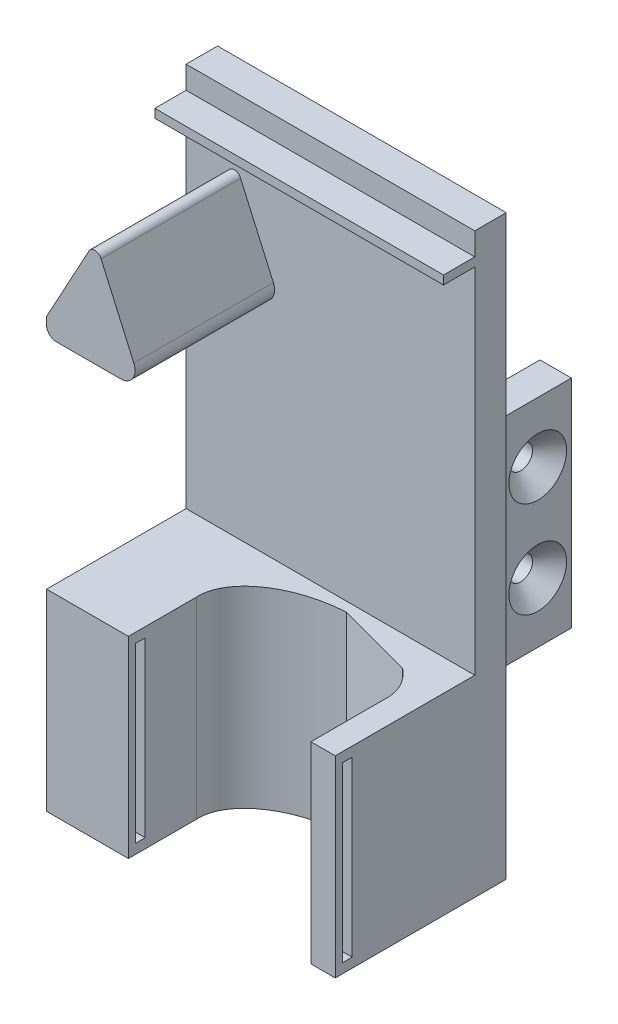
from build123d import *

# Parameters (mm, degrees)
SKETCH1_W                                       = 60
SKETCH1_H                                       = 120
BOSS_EXTRUDE1_DEPTH                             = 6.54
SKETCH10_W                                      = 6.54
SKETCH10_H                                      = 45
BOSS_EXTRUDE5_DEPTH                             = 17
SKETCH17_W                                      = 60
SKETCH17_H                                      = 40
BOSS_EXTRUDE6_DEPTH                             = 29
CUT_EXTRUDE1_REACH                              = 42
CUT_EXTRUDE2_REACH                              = 54.54
SKETCH21_W                                      = 37.9445377
SKETCH21_H                                      = 40
SKETCH23_W                                      = 2
SKETCH23_H                                      = 36
CUT_EXTRUDE3_DEPTH                              = 9
SKETCH24_W                                      = 2
SKETCH24_H                                      = 36
CUT_EXTRUDE4_DEPTH                              = 9
CSK_FOR_M3_FLAT_HEAD_MACHINE_SCREW4_D           = 4.93
CSK_FOR_M3_FLAT_HEAD_MACHINE_SCREW4_DEPTH       = 6.54
CSK_FOR_M3_FLAT_HEAD_MACHINE_SCREW4_CSINK_D     = 12
CSK_FOR_M3_FLAT_HEAD_MACHINE_SCREW4_CSINK_ANGLE = 90
CSK_FOR_M3_FLAT_HEAD_MACHINE_SCREW5_D           = 4.93
CSK_FOR_M3_FLAT_HEAD_MACHINE_SCREW5_DEPTH       = 6.54
CSK_FOR_M3_FLAT_HEAD_MACHINE_SCREW5_CSINK_D     = 12
CSK_FOR_M3_FLAT_HEAD_MACHINE_SCREW5_CSINK_ANGLE = 90
BOSS_EXTRUDE8_DEPTH                             = 29
SKETCH36_W                                      = 60
SKETCH36_H                                      = 1.8
BOSS_EXTRUDE9_DEPTH                             = 6.5
FILLET1_R                                       = 3
FILLET2_R                                       = 2


with BuildPart() as part:
    # Sketch1 → Boss-Extrude1 (new body)
    with BuildSketch(Plane.XY):
        Rectangle(SKETCH1_W, SKETCH1_H)
    extrude(amount=BOSS_EXTRUDE1_DEPTH)

    # Sketch10 → Boss-Extrude5 (add)
    with BuildSketch(Plane(origin=(0, 0, 0), x_dir=(-1, 0, 0), z_dir=(0, 0, -1))):
        with Locations((23.27, -2.5)):
            Rectangle(SKETCH10_W, SKETCH10_H)
        with Locations((-23.27, -2.5)):
            Rectangle(SKETCH10_W, SKETCH10_H)
    extrude(amount=BOSS_EXTRUDE5_DEPTH)

    # Sketch17 → Boss-Extrude6 (add)
    with BuildSketch(Plane.XY.offset(6.54)):
        with Locations((0, -40)):
            Rectangle(SKETCH17_W, SKETCH17_H)
    extrude(amount=BOSS_EXTRUDE6_DEPTH)

    # Sketch18 → Cut-Extrude1 (cut, up to next)
    with BuildSketch(Plane(origin=(0, -20, 0), x_dir=(1, 0, 0), z_dir=(0, 1, 0)), mode=Mode.PRIVATE) as cut_extrude1_sk1:
        with BuildLine():
            Line((5.334966353, -8.526396136), (21.291300905, -12.825812438))
            add(Edge.make_bspline(
                [(5.334966353, -8.526396136), (-17.854714365, -9.780670981), (-12.49786254, -23.648890313), (-7.141010715, -37.517109645), (13.926544327, -30.768916863), (34.994099369, -24.020724082), (21.291300905, -12.825812438)],
                knots=[1.570796327, 1.570796327, 1.570796327, 3.340987112, 3.340987112, 5.111177898, 5.111177898, 6.881368684, 6.881368684, 6.881368684], degree=2, weights=[1, 0.633215673, 1, 0.633215673, 1, 0.633215673, 1]))
        make_face()
    cut_extrude1_tool1 = extrude(cut_extrude1_sk1.sketch, amount=-CUT_EXTRUDE1_REACH, mode=Mode.PRIVATE) & part.part
    add(cut_extrude1_tool1.solids().sort_by_distance((5.792514, -20, 20.554542))[0], mode=Mode.SUBTRACT)

    # Sketch21 → Cut-Extrude2 (cut, up to next)
    with BuildSketch(Plane.XY.offset(35.54), mode=Mode.PRIVATE) as cut_extrude2_sk1:
        with Locations((5.97226885, -40)):
            Rectangle(SKETCH21_W, SKETCH21_H)
    cut_extrude2_tool1 = extrude(cut_extrude2_sk1.sketch, amount=-CUT_EXTRUDE2_REACH, mode=Mode.PRIVATE) & part.part
    add(cut_extrude2_tool1.solids().sort_by_distance((5.972269, -40, 35.54))[0], mode=Mode.SUBTRACT)

    # Sketch23 → Cut-Extrude3 (cut)
    with BuildSketch(Plane(origin=(-13, 0, 0), x_dir=(0, 0, -1), z_dir=(1, 0, 0))):
        with Locations((-33.04, -40)):
            Rectangle(SKETCH23_W, SKETCH23_H)
    extrude(amount=-CUT_EXTRUDE3_DEPTH, mode=Mode.SUBTRACT)

    # Sketch24 → Cut-Extrude4 (cut)
    with BuildSketch(Plane.ZY.offset(-24.9445377)):
        with Locations((33.04, -40)):
            Rectangle(SKETCH24_W, SKETCH24_H)
    extrude(amount=-CUT_EXTRUDE4_DEPTH, mode=Mode.SUBTRACT)

    # CSK for M3 Flat Head Machine Screw4
    with Locations(Plane(origin=(26.54, -12.5, -10), x_dir=(0, 1, 0), z_dir=(1, 0, 0))):
        with Locations((0, 0), (20, 0)):
            CounterSinkHole(CSK_FOR_M3_FLAT_HEAD_MACHINE_SCREW4_D / 2, CSK_FOR_M3_FLAT_HEAD_MACHINE_SCREW4_CSINK_D / 2, depth=CSK_FOR_M3_FLAT_HEAD_MACHINE_SCREW4_DEPTH, counter_sink_angle=CSK_FOR_M3_FLAT_HEAD_MACHINE_SCREW4_CSINK_ANGLE)

    # CSK for M3 Flat Head Machine Screw5
    with Locations(Plane(origin=(-26.54, -12.5, -10), x_dir=(0, -1, 0), z_dir=(-1, 0, 0))):
        with Locations((0, 0), (-20, 0)):
            CounterSinkHole(CSK_FOR_M3_FLAT_HEAD_MACHINE_SCREW5_D / 2, CSK_FOR_M3_FLAT_HEAD_MACHINE_SCREW5_CSINK_D / 2, depth=CSK_FOR_M3_FLAT_HEAD_MACHINE_SCREW5_DEPTH, counter_sink_angle=CSK_FOR_M3_FLAT_HEAD_MACHINE_SCREW5_CSINK_ANGLE)

    # Sketch7 → Boss-Extrude8 (add)
    with BuildSketch(Plane.XY.offset(6.54)):
        with BuildLine():
            Line((-10, 25.533918981), (-18.67330273, 45.101562584))
            ThreePointArc((-18.67330273, 45.101562584), (-20, 46), (-21.305734932, 45.071360283))
            Line((-21.305734932, 45.071360283), (-30, 29.115374119))
            Line((-30, 29.115374119), (-30, 25.533918981))
            Line((-30, 25.533918981), (-10, 25.533918981))
        make_face()
    extrude(amount=BOSS_EXTRUDE8_DEPTH)

    # Sketch36 → Boss-Extrude9 (add)
    with BuildSketch(Plane.XY.offset(6.54)):
        with Locations((0, 54.4)):
            Rectangle(SKETCH36_W, SKETCH36_H)
    extrude(amount=BOSS_EXTRUDE9_DEPTH)

    # Fillet1
    fillet1_edges = [part.edges().sort_by_distance(p)[0] for p in [
        (-10, 25.533918981, 21.04),
    ]]
    fillet(fillet1_edges, radius=FILLET1_R)

    # Fillet2
    fillet2_edges = [part.edges().sort_by_distance(p)[0] for p in [
        (-30, 25.533918981, 21.04),
    ]]
    fillet(fillet2_edges, radius=FILLET2_R)


solid = part.part
